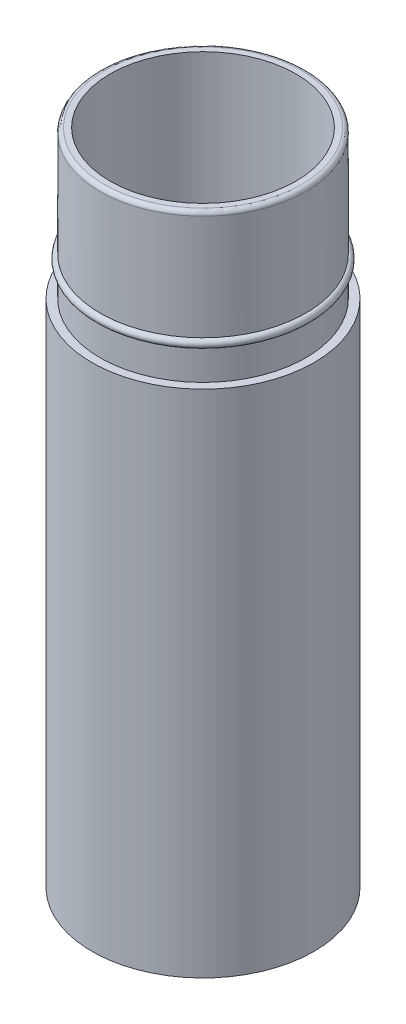
from build123d import *

# Parameters (mm, degrees)
FILLET1_R = 0.5


with BuildPart() as part:
    # Sketch1 → Revolve1 (revolve)
    with BuildSketch(Plane.XY):
        with BuildLine():
            Line((11.3, 0), (11.3, 80))
            Line((11.3, 80), (12.5, 80))
            Line((12.5, 80), (12.5, 66.7))
            ThreePointArc((12.5, 66.7), (13, 66.2), (12.5, 65.7))
            Line((12.5, 65.7), (12.5, 62))
            Line((12.5, 62), (13.5, 62))
            Line((13.5, 62), (13.5, 0))
            Line((13.5, 0), (11.3, 0))
        make_face()
    revolve(axis=Axis((0, 52.2625, 0), (0, -1, 0)))

    # Fillet1
    fillet1_edges = [part.edges().sort_by_distance(p)[0] for p in [
        (-12.5, 80, 0),
    ]]
    fillet(fillet1_edges, radius=FILLET1_R)


solid = part.part
